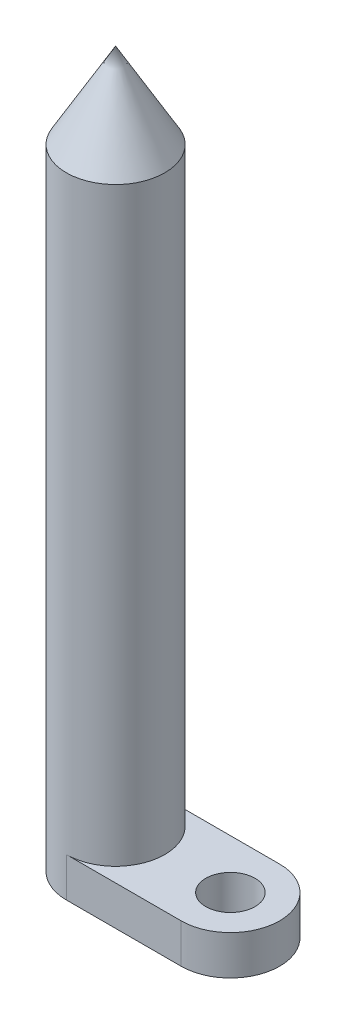
from build123d import *

# Parameters (mm, degrees)
SKETCH1_R           = 7.5
BOSS_EXTRUDE1_DEPTH = 12
SKETCH2_R           = 15
BOSS_EXTRUDE2_DEPTH = 180


with BuildPart() as part:
    # Sketch1 → Boss-Extrude1 (new body)
    with BuildSketch(Plane(origin=(0, 0, 0), x_dir=(1, 0, 0), z_dir=(0, 1, 0))):
        with BuildLine():
            Line((0, 15), (35, 15))
            ThreePointArc((35, 15), (50, 0), (35, -15))
            Line((35, -15), (0, -15))
            ThreePointArc((0, -15), (-15, 0), (0, 15))
        make_face()
        with Locations(Location((35, 0, 0), (0, 0, 270))):  # turned: the seam where the file's is
            Circle(SKETCH1_R, mode=Mode.SUBTRACT)
    extrude(amount=BOSS_EXTRUDE1_DEPTH)

    # Sketch2 → Boss-Extrude2 (add)
    with BuildSketch(Plane(origin=(0, 12, 0), x_dir=(1, 0, 0), z_dir=(0, 1, 0))):
        with Locations(Location((0, 0, 0), (0, 0, 270))):  # turned: the seam where the file's is
            Circle(SKETCH2_R)
    extrude(amount=BOSS_EXTRUDE2_DEPTH)

    # Sketch3 → Revolve1 (revolve)
    with BuildSketch(Plane(origin=(0, 0, 0), x_dir=(0, 0, -1), z_dir=(1, 0, 0)), mode=Mode.PRIVATE) as revolve1_sk:
        Polygon((15, 192), (0, 192), (0, 217.980762114), align=None)
    revolve(revolve1_sk.sketch.rotate(Axis((0, -19.330259434, 0), (0, 1, 0)), 180), axis=Axis((0, -19.330259434, 0), (0, 1, 0)))  # turned: the seam where the file's is


solid = part.part
